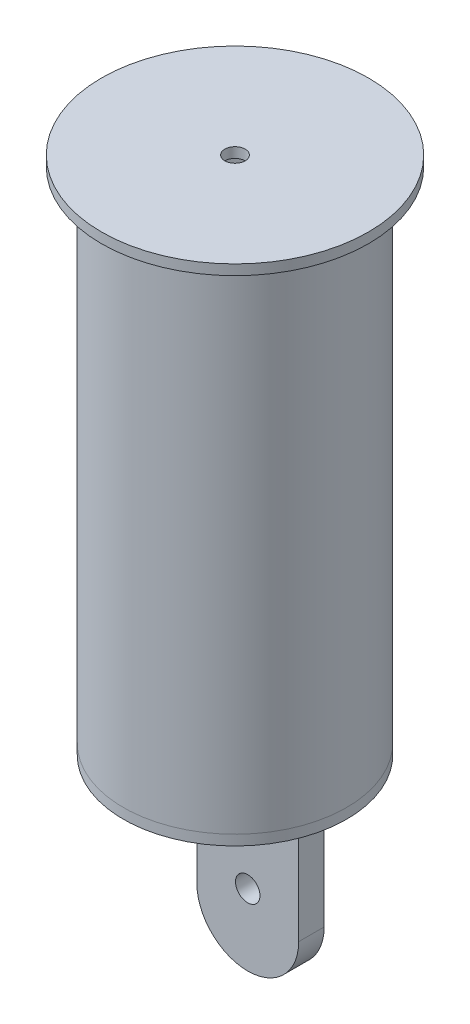
from build123d import *

# Parameters (mm, degrees)
ESBO_O3_R                = 109.54
RESSALTO_EXTRUS_O1_DEPTH = 10
RESSALTO_EXTRUS_O2_START = -12.5
ESBO_O4_R                = 12
RESSALTO_EXTRUS_O2_DEPTH = 25


with BuildPart() as part:
    # Esboço1 → Revolução1 (revolve)
    with BuildSketch(Plane.XY):
        Polygon((10, 500), (131, 500), (131, 490), (109.54, 490), (109.54, 0), (103.54, 0), (103.54, 490), (10, 490), align=None)
    revolve(axis=Axis((0, 0, 0), (0, 1, 0)))


with BuildPart() as body_2:
    # Esboço3 → Ressalto-extrusão1 (new body)
    with BuildSketch(Plane.XZ):
        Circle(ESBO_O3_R)
    extrude(amount=RESSALTO_EXTRUS_O1_DEPTH)

    # Esboço4 → Ressalto-extrusão2 (add)
    with BuildSketch(Plane.XY.offset(RESSALTO_EXTRUS_O2_START)):
        with BuildLine():
            Line((-50, -10), (-50, -150))
            ThreePointArc((-50, -150), (0, -200), (50, -150))
            Line((50, -150), (50, -10))
            Line((50, -10), (-50, -10))
        make_face()
        with Locations((0, -130)):
            Circle(ESBO_O4_R, mode=Mode.SUBTRACT)
    extrude(amount=-RESSALTO_EXTRUS_O2_DEPTH)


solid = Compound([part.part, body_2.part])
